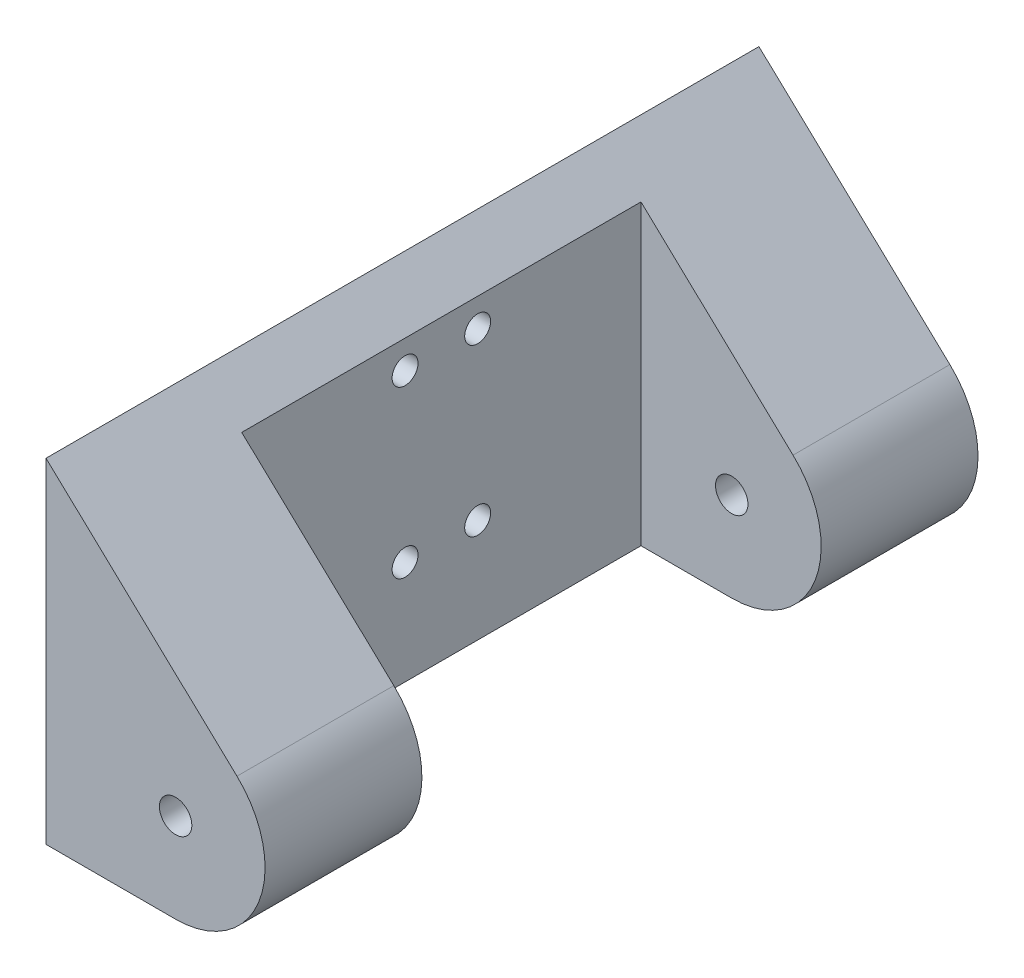
from build123d import *

# Parameters (mm, degrees)
SKETCH1_W           = 70
SKETCH1_H           = 3
BOSS_EXTRUDE1_DEPTH = 55
SKETCH2_W           = 70
SKETCH2_H           = 2.5
BOSS_EXTRUDE2_DEPTH = 22.8
SKETCH5_R           = 3.5
CUT_EXTRUDE1_DEPTH  = 84.8
SKETCH6_W           = 16
SKETCH6_H           = 11.6
SKETCH6_W_2         = 15
BOSS_EXTRUDE7_DEPTH = 22.8
SKETCH7_R           = 1
CUT_EXTRUDE2_DEPTH  = 8
SKETCH8_R           = 1
CUT_EXTRUDE3_DEPTH  = 8
FILLET1_R           = 5
SKETCH9_W           = 14.084433838
SKETCH9_H           = 7
CUT_EXTRUDE4_DEPTH  = 66
SKETCH10_R          = 1.25
BOSS_EXTRUDE8_DEPTH = 55
SKETCH11_W          = 19.22261198
SKETCH11_H          = 30.8
CUT_EXTRUDE5_DEPTH  = 35
SKETCH12_W          = 30.8
SKETCH12_H          = 25.8
SKETCH12_R          = 1
BOSS_EXTRUDE9_DEPTH = 3
CUT_EXTRUDE6_DEPTH  = 96
SKETCH14_W          = 89.735472453
SKETCH14_H          = 73.087764116
CUT_EXTRUDE7_DEPTH  = 96


with BuildPart() as part:
    # Sketch1 → Boss-Extrude1 (new body)
    with BuildSketch(Plane.XY):
        Rectangle(SKETCH1_W, SKETCH1_H)
    extrude(amount=BOSS_EXTRUDE1_DEPTH)

    # Sketch2 → Boss-Extrude2 (add)
    with BuildSketch(Plane(origin=(0, 1.5, 0), x_dir=(1, 0, 0), z_dir=(0, 1, 0))):
        with Locations((0, -1.25)):
            Rectangle(SKETCH2_W, SKETCH2_H)
        with Locations((0, -53.75)):
            Rectangle(SKETCH2_W, SKETCH2_H)
    extrude(amount=BOSS_EXTRUDE2_DEPTH)

    # Sketch5 → Cut-Extrude1 (cut)
    with BuildSketch(Plane.XY.offset(55)):
        with Locations((-24, 11.4)):
            Circle(SKETCH5_R)
    extrude(amount=-CUT_EXTRUDE1_DEPTH, mode=Mode.SUBTRACT)

    # Sketch6 → Boss-Extrude7 (add)
    with BuildSketch(Plane(origin=(0, 24.3, 0), x_dir=(1, 0, 0), z_dir=(0, 1, 0))):
        with Locations((-7, -27.5)):
            Rectangle(SKETCH6_W, SKETCH6_H)
        with Locations((27.5, -27.5)):
            Rectangle(SKETCH6_W_2, SKETCH6_H)
    extrude(amount=-BOSS_EXTRUDE7_DEPTH)

    # Sketch7 → Cut-Extrude2 (cut)
    with BuildSketch(Plane(origin=(0, 24.3, 0), x_dir=(1, 0, 0), z_dir=(0, 1, 0))):
        with Locations((-12, -24.7)):
            Circle(SKETCH7_R)
        with Locations((23, -30.3)):
            Circle(SKETCH7_R)
        with Locations((-2, -24.7)):
            Circle(SKETCH7_R)
        with Locations((-2, -30.3)):
            Circle(SKETCH7_R)
        with Locations((-12, -30.3)):
            Circle(SKETCH7_R)
        with Locations((23, -24.7)):
            Circle(SKETCH7_R)
        with Locations((32, -24.7)):
            Circle(SKETCH7_R)
        with Locations((32, -30.3)):
            Circle(SKETCH7_R)
    extrude(amount=-CUT_EXTRUDE2_DEPTH, mode=Mode.SUBTRACT)

    # Sketch8 → Cut-Extrude3 (cut)
    with BuildSketch(Plane(origin=(35, 0, 0), x_dir=(0, 0, -1), z_dir=(1, 0, 0))):
        with Locations((-24.7, 19.3)):
            Circle(SKETCH8_R)
        with Locations((-30.3, 19.3)):
            Circle(SKETCH8_R)
        with Locations((-24.7, 6.5)):
            Circle(SKETCH8_R)
        with Locations((-30.3, 6.5)):
            Circle(SKETCH8_R)
    extrude(amount=-CUT_EXTRUDE3_DEPTH, mode=Mode.SUBTRACT)

    # Fillet1
    fillet1_edges = [part.edges().sort_by_distance(p)[0] for p in [
        (1, 1.5, 27.5),
        (-15, 1.5, 27.5),
        (20, 1.5, 27.5),
    ]]
    fillet(fillet1_edges, radius=FILLET1_R)

    # Sketch9 → Cut-Extrude4 (cut)
    with BuildSketch(Plane.XY.offset(55)):
        with Locations((-31.042216919, 11.4)):
            Rectangle(SKETCH9_W, SKETCH9_H)
    extrude(amount=-CUT_EXTRUDE4_DEPTH, mode=Mode.SUBTRACT)

    # Sketch10 → Boss-Extrude8 (add)
    with BuildSketch(Plane.XY.offset(55)):
        with BuildLine():
            Line((35, 24.3), (49.731333151, 10.422398492))
            ThreePointArc((49.731333151, 10.422398492), (51.413444846, 2.85486244), (45, -1.5))
            Line((45, -1.5), (35, -1.5))
            Line((35, -1.5), (35, 24.3))
        make_face()
        with Locations((45, 5.4)):
            Circle(SKETCH10_R, mode=Mode.SUBTRACT)
    extrude(amount=-BOSS_EXTRUDE8_DEPTH)

    # Sketch11 → Cut-Extrude5 (cut)
    with BuildSketch(Plane.XZ.offset(1.5)):
        with Locations((44.61130599, 27.5)):
            Rectangle(SKETCH11_W, SKETCH11_H)
    extrude(amount=-CUT_EXTRUDE5_DEPTH, mode=Mode.SUBTRACT)

    # Sketch12 → Boss-Extrude9 (add)
    with BuildSketch(Plane(origin=(35, 0, 0), x_dir=(0, 0, -1), z_dir=(1, 0, 0))):
        with Locations((-27.5, 11.4)):
            Rectangle(SKETCH12_W, SKETCH12_H)
        with Locations((-30.3, 19.3)):
            Circle(SKETCH12_R, mode=Mode.SUBTRACT)
        with Locations((-30.3, 6.5)):
            Circle(SKETCH12_R, mode=Mode.SUBTRACT)
        with Locations((-24.7, 6.5)):
            Circle(SKETCH12_R, mode=Mode.SUBTRACT)
        with Locations((-24.7, 19.3)):
            Circle(SKETCH12_R, mode=Mode.SUBTRACT)
    extrude(amount=BOSS_EXTRUDE9_DEPTH)

    # Sketch13 → Cut-Extrude6 (cut)
    with BuildSketch(Plane(origin=(0, 0, 0), x_dir=(-1, 0, 0), z_dir=(0, 0, -1))):
        Polygon((-35, 24.3), (-38, 21.473860363), (-40.585256697, 23.898774346), (-37.538023225, 25.511318129), align=None)
    extrude(amount=-CUT_EXTRUDE6_DEPTH, mode=Mode.SUBTRACT)

    # Sketch14 → Cut-Extrude7 (cut)
    with BuildSketch(Plane(origin=(0, 24.3, 0), x_dir=(1, 0, 0), z_dir=(0, 1, 0))):
        with Locations((-9.867736226, -18.456117942)):
            Rectangle(SKETCH14_W, SKETCH14_H)
    extrude(amount=-CUT_EXTRUDE7_DEPTH, mode=Mode.SUBTRACT)


solid = part.part
